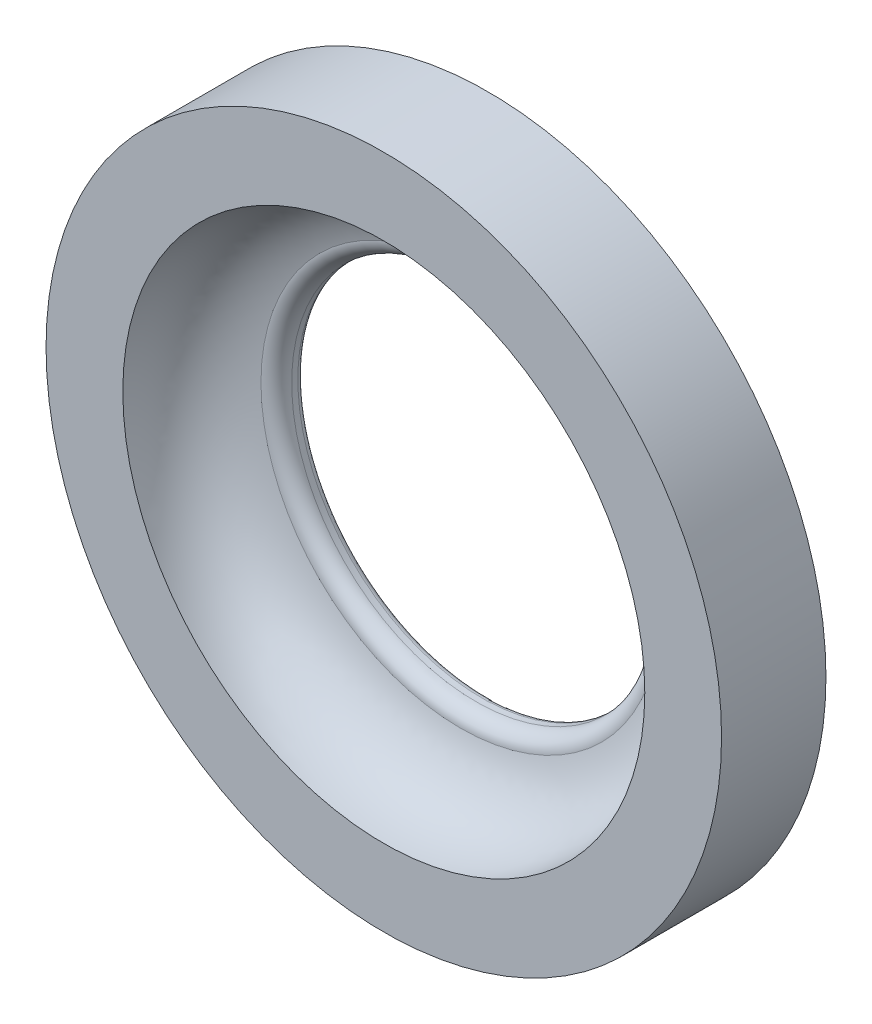
from build123d import *


with BuildPart() as part:
    # Sketch2 → Revolve1 (revolve)
    with BuildSketch(Plane(origin=(0, 0, 0), x_dir=(1, 0, 0), z_dir=(0, 1, 0))):
        with BuildLine():
            Line((-5.5, 0), (-5.5, 1.7))
            Line((-5.5, 1.7), (-3.1, 1.7))
            ThreePointArc((-3.1, 1.7), (-3.029289322, 1.670710678), (-3, 1.6))
            Line((-3, 1.6), (-3, 1.5))
            ThreePointArc((-3, 1.5), (-3.073223305, 1.323223305), (-3.25, 1.25))
            add(Edge.make_bspline(
                [(-4.25, 0), (-4.226841552, 1.005477645), (-3.25, 1.25)],
                knots=[0, 0, 0, 1, 1, 1], degree=2))
            Line((-4.25, 0), (-5.5, 0))
        make_face()
    revolve(axis=Axis((0, 0, 0), (0, 0, -1)))


solid = part.part
